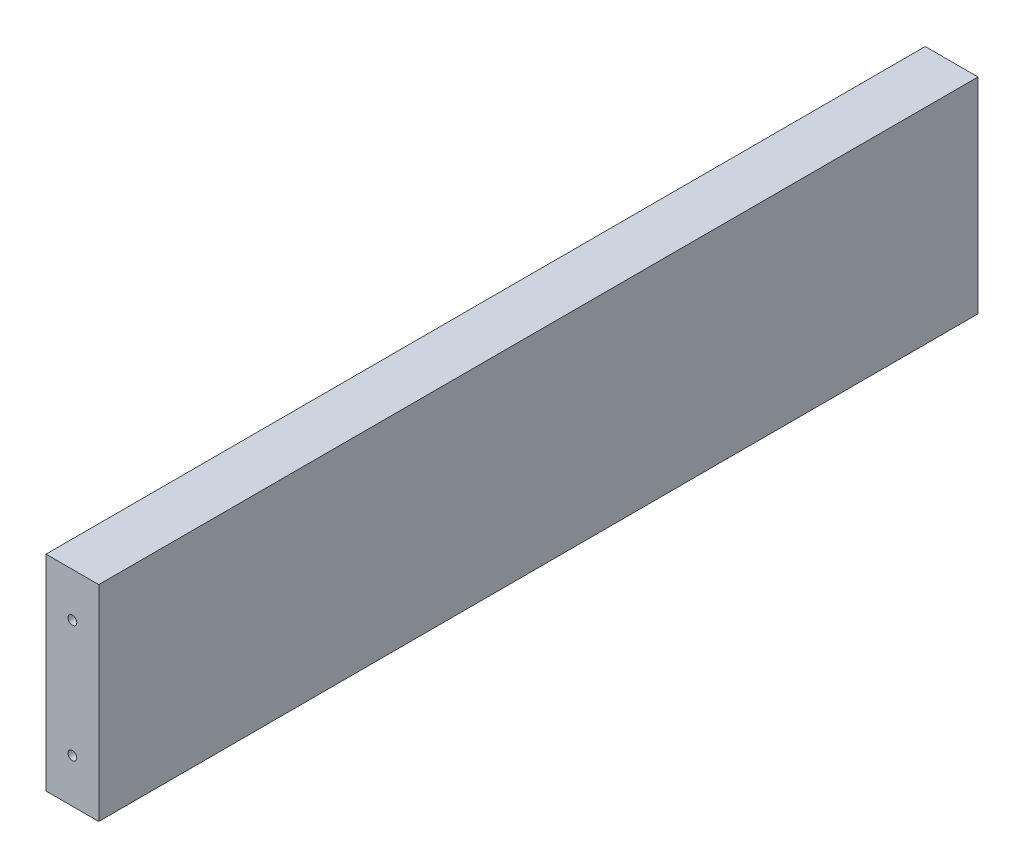
from build123d import *

# Parameters (mm, degrees)
CROQUIS7_W              = 300
CROQUIS7_H              = 70
CROQUIS7_R              = 1.5
SALIENTE_EXTRUIR4_DEPTH = 18
CROQUIS8_R              = 1.5
CORTAR_EXTRUIR1_DEPTH   = 12
CROQUIS9_R              = 1.5
CORTAR_EXTRUIR2_DEPTH   = 12
CROQUIS14_R             = 1.5
SALIENTE_EXTRUIR9_DEPTH = 12


with BuildPart() as part:
    # Croquis7 → Saliente-Extruir4 (new body)
    with BuildSketch(Plane(origin=(-150, 0, 0), x_dir=(0, 0, -1), z_dir=(1, 0, 0))):
        Rectangle(CROQUIS7_W, CROQUIS7_H)
        with Locations((90, 7.5)):
            Circle(CROQUIS7_R, mode=Mode.SUBTRACT)
        with Locations((140, 7.5)):
            Circle(CROQUIS7_R, mode=Mode.SUBTRACT)
        with Locations((90, -7.5)):
            Circle(CROQUIS7_R, mode=Mode.SUBTRACT)
        with Locations((140, -7.5)):
            Circle(CROQUIS7_R, mode=Mode.SUBTRACT)
    extrude(amount=SALIENTE_EXTRUIR4_DEPTH)

    # Croquis8 → Cortar-Extruir1 (cut)
    with BuildSketch(Plane.XY.offset(150)):
        with Locations((-141, -20)):
            Circle(CROQUIS8_R)
        with Locations((-141, 20)):
            Circle(CROQUIS8_R)
    extrude(amount=-CORTAR_EXTRUIR1_DEPTH, mode=Mode.SUBTRACT)

    # Croquis9 → Cortar-Extruir2 (cut)
    with BuildSketch(Plane(origin=(0, 0, -150), x_dir=(-1, 0, 0), z_dir=(0, 0, -1))):
        with Locations((141, -20)):
            Circle(CROQUIS9_R)
        with Locations((141, 20)):
            Circle(CROQUIS9_R)
    extrude(amount=-CORTAR_EXTRUIR2_DEPTH, mode=Mode.SUBTRACT)

    # Croquis14 → Saliente-Extruir9 (add)
    with BuildSketch(Plane(origin=(-132, 0, 0), x_dir=(0, 0, -1), z_dir=(1, 0, 0))):
        with Locations((140, -7.5)):
            Circle(CROQUIS14_R)
        with Locations((140, 7.5)):
            Circle(CROQUIS14_R)
        with Locations((90, -7.5)):
            Circle(CROQUIS14_R)
        with Locations((90, 7.5)):
            Circle(CROQUIS14_R)
    extrude(amount=-SALIENTE_EXTRUIR9_DEPTH)


solid = part.part
